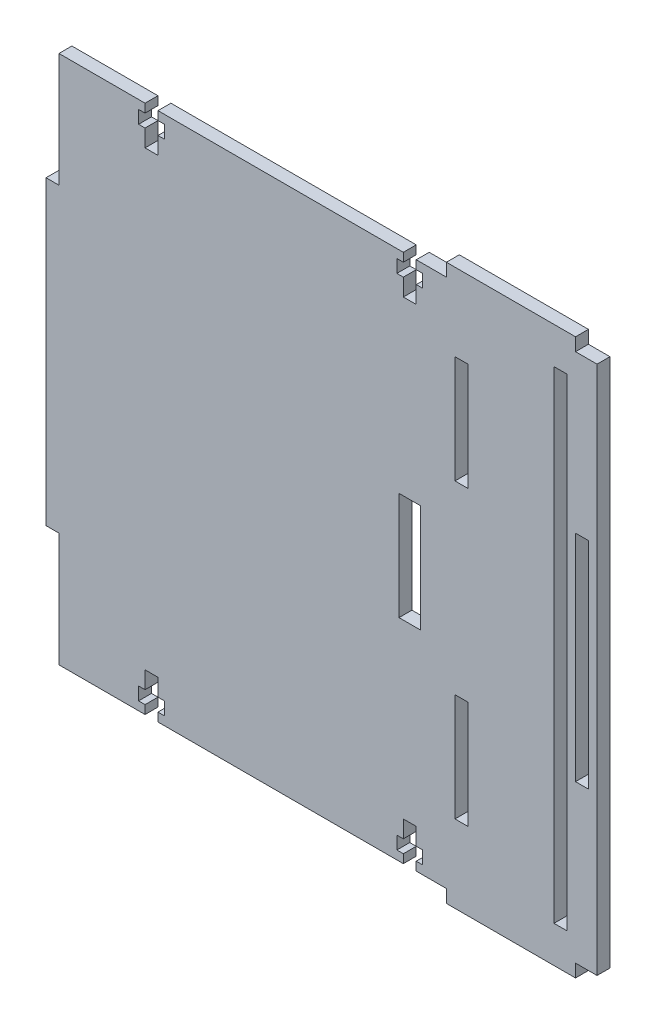
from build123d import *

# Parameters (mm, degrees)
SKETCH1_W           = 5
SKETCH1_H           = 25
SKETCH1_W_2         = 3
SKETCH1_H_2         = 50
SKETCH1_H_3         = 112
BOSS_EXTRUDE2_DEPTH = 3


with BuildPart() as part:
    # Sketch1 → Boss-Extrude2 (new body)
    with BuildSketch(Plane.XY):
        Polygon((17.5, 52.5), (20.5, 52.5), (20.5, 56.5), (22, 56.5), (22, 59.5), (20.5, 59.5), (20.5, 61.5), (27.5, 61.5), (27.5, 64.5), (57.5, 64.5), (57.5, 61.5), (62.5, 61.5), (62.5, -61.5), (57.5, -61.5), (57.5, -64.5), (27.5, -64.5), (27.5, -61.5), (20.5, -61.5), (20.5, -59.5), (22, -59.5), (22, -56.5), (20.5, -56.5), (20.5, -52.5), (17.5, -52.5), (17.5, -56.5), (16, -56.5), (16, -59.5), (17.5, -59.5), (17.5, -61.5), (-39.5, -61.5), (-39.5, -59.5), (-38, -59.5), (-38, -56.5), (-39.5, -56.5), (-39.5, -52.5), (-42.5, -52.5), (-42.5, -56.5), (-44, -56.5), (-44, -59.5), (-42.5, -59.5), (-42.5, -61.5), (-62.5, -61.5), (-62.5, -35), (-65.5, -35), (-65.5, 35), (-62.5, 35), (-62.5, 61.5), (-42.5, 61.5), (-42.5, 59.5), (-44, 59.5), (-44, 56.5), (-42.5, 56.5), (-42.5, 52.5), (-39.5, 52.5), (-39.5, 56.5), (-38, 56.5), (-38, 59.5), (-39.5, 59.5), (-39.5, 61.5), (17.5, 61.5), (17.5, 59.5), (16, 59.5), (16, 56.5), (17.5, 56.5), align=None)
        with Locations((19, 0)):
            Rectangle(SKETCH1_W, SKETCH1_H, mode=Mode.SUBTRACT)
        with Locations((59, 0)):
            Rectangle(SKETCH1_W_2, SKETCH1_H_2, mode=Mode.SUBTRACT)
        with Locations((31, -34)):
            Rectangle(SKETCH1_W_2, SKETCH1_H, mode=Mode.SUBTRACT)
        with Locations((31, 34)):
            Rectangle(SKETCH1_W_2, SKETCH1_H, mode=Mode.SUBTRACT)
        with Locations((54, 0)):
            Rectangle(SKETCH1_W_2, SKETCH1_H_3, mode=Mode.SUBTRACT)
    extrude(amount=BOSS_EXTRUDE2_DEPTH)


solid = part.part
